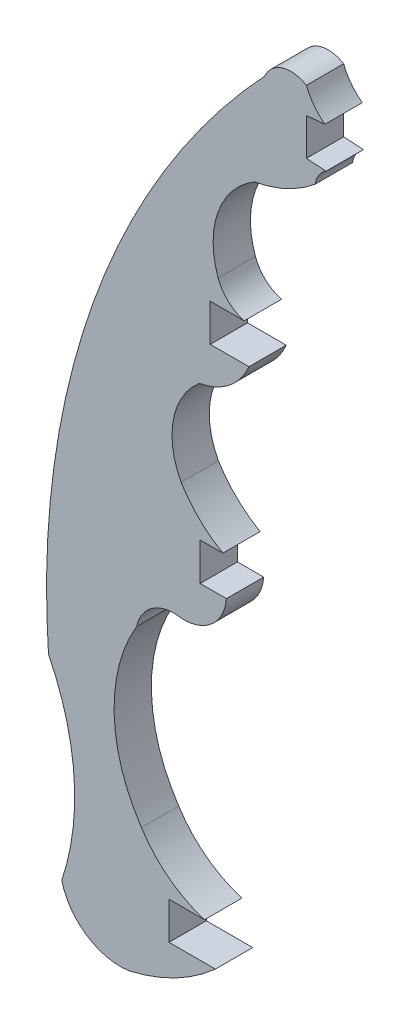
from build123d import *

# Parameters (mm, degrees)
BOSS_EXTRUDE1_DEPTH = 1.524


with BuildPart() as part:
    # Sketch1 → Boss-Extrude1 (new body)
    with BuildSketch(Plane.XY):
        with BuildLine():
            Line((-110.824360774, 0), (-110.824360774, -1.524))
            Line((-110.824360774, -1.524), (-108.927743626, -1.524))
            ThreePointArc((-108.927743626, -1.524), (-110.568786986, -2.659932295), (-112.442883949, -3.346318527))
            ThreePointArc((-112.442883949, -3.346318527), (-114.17716098, -2.968961004), (-115.207793415, -1.524))
            ThreePointArc((-115.207793415, -1.524), (-114.703070876, 2.396926331), (-115.749307819, 6.209247985))
            ThreePointArc((-115.749307819, 6.209247985), (-113.92263745, 19.565030778), (-106.916865485, 31.081663004))
            ThreePointArc((-106.916865485, 31.081663004), (-106.184950927, 31.736506317), (-105.211200263, 31.608723968))
            ThreePointArc((-105.211200263, 31.608723968), (-104.901513118, 31.0579276), (-104.454303839, 30.611512291))
            Line((-104.454303839, 30.611512291), (-105.211200263, 30.544825407))
            Line((-105.211200263, 30.544825407), (-105.211200263, 29.025368505))
            Line((-105.211200263, 29.025368505), (-104.403994808, 28.977437337))
            ThreePointArc((-104.403994808, 28.977437337), (-104.700603167, 28.683060455), (-104.849681876, 28.292663471))
            ThreePointArc((-104.849681876, 28.292663471), (-106.016123504, 27.550057971), (-107.333979522, 27.131364149))
            ThreePointArc((-107.333979522, 27.131364149), (-108.818673483, 25.32832607), (-108.817338403, 22.992676119))
            ThreePointArc((-108.817338403, 22.992676119), (-108.405188947, 22.369705182), (-107.752531072, 22.00639036))
            Line((-107.752531072, 22.00639036), (-109.139263732, 22.00639036))
            Line((-109.139263732, 22.00639036), (-109.139263732, 20.478701595))
            Line((-109.139263732, 20.478701595), (-107.557691458, 20.478701595))
            ThreePointArc((-107.557691458, 20.478701595), (-108.363599409, 19.419942847), (-109.579185571, 18.87882549))
            ThreePointArc((-109.579185571, 18.87882549), (-110.645223511, 17.073742216), (-110.328866367, 15.001381081))
            ThreePointArc((-110.328866367, 15.001381081), (-109.579185571, 14.069438674), (-108.625140976, 13.348094888))
            Line((-108.625140976, 13.348094888), (-109.551135599, 13.348094888))
            Line((-109.551135599, 13.348094888), (-109.551135599, 11.811176348))
            Line((-109.551135599, 11.811176348), (-108.478697007, 11.811176348))
            ThreePointArc((-108.478697007, 11.811176348), (-109.071957304, 10.623612067), (-110.328866367, 10.196474724))
            ThreePointArc((-110.328866367, 10.196474724), (-111.484723908, 9.970154225), (-112.1438695, 8.994062677))
            ThreePointArc((-112.1438695, 8.994062677), (-113.066844869, 5.45696931), (-111.950245848, 1.976147619))
            ThreePointArc((-111.950245848, 1.976147619), (-110.838027473, 0.758299628), (-109.373389254, 0))
            Line((-109.373389254, 0), (-110.824360774, 0))
        make_face()
    extrude(amount=BOSS_EXTRUDE1_DEPTH)


solid = part.part
